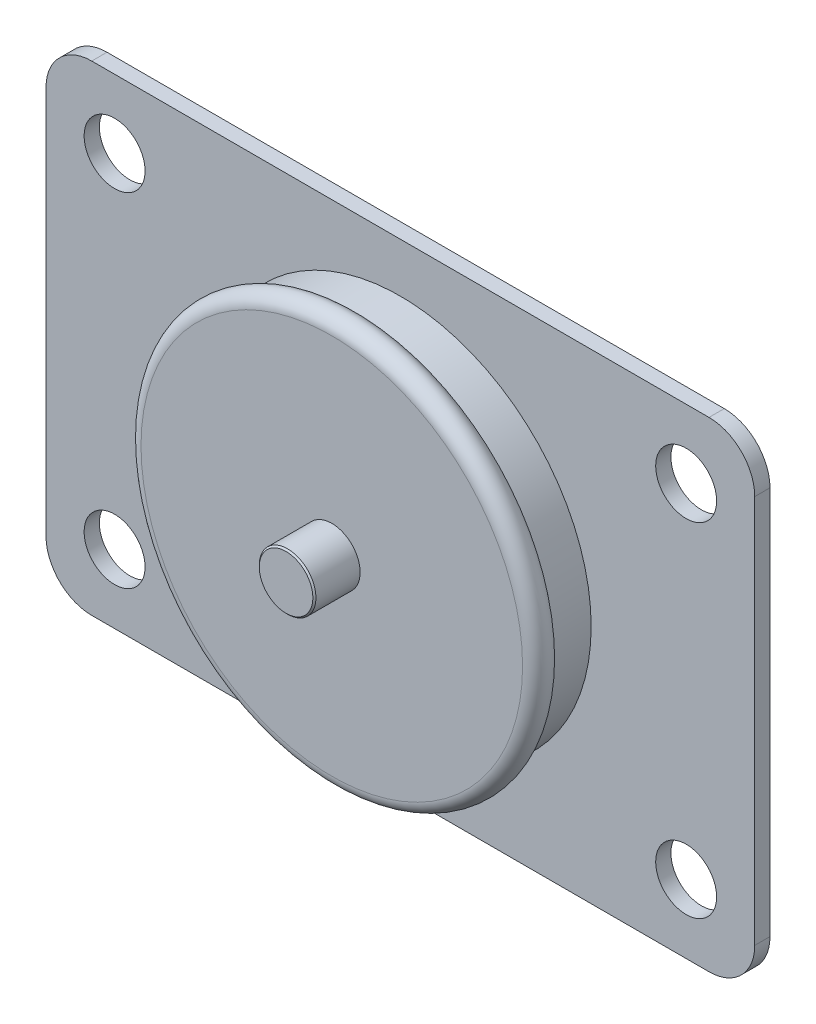
from build123d import *

# Parameters (mm, degrees)
EXTRUDE_1_DEPTH     = 2
SKETCH_4_R          = 25.034791669
EXTRUDE_2_DEPTH     = 9
SKETCH_5_R          = 1.739871364
SKETCH_7_R          = 3.716982855
EXTRUDE_3_DEPTH     = 6
CHAMFER_1_SIZE      = 0.2
SKETCH_9_R          = 25
CUT_EXTRUDE_2_DEPTH = 0.36
EXTRUDE_4_DEPTH     = 2
SKETCH_13_R         = 4
CUT_EXTRUDE_3_DEPTH = 35


with BuildPart() as part:
    # 草图1 → 凸台-拉伸1 (new body)
    with BuildSketch(Plane.XY):
        with BuildLine():
            Line((40.5, -31.5), (-40.5, -31.5))
            ThreePointArc((-40.5, -31.5), (-44.742640687, -29.742640687), (-46.5, -25.5))
            Line((-46.5, -25.5), (-46.5, 25.5))
            ThreePointArc((-46.5, 25.5), (-44.742640687, 29.742640687), (-40.5, 31.5))
            Line((-40.5, 31.5), (40.5, 31.5))
            ThreePointArc((40.5, 31.5), (44.742640687, 29.742640687), (46.5, 25.5))
            Line((46.5, 25.5), (46.5, -25.5))
            ThreePointArc((46.5, -25.5), (44.742640687, -29.742640687), (40.5, -31.5))
        make_face()
        with BuildLine():
            Line((-43.156854249, 22.5), (-37.5, 28.156854249))
            ThreePointArc((-37.5, 28.156854249), (-31.843145751, 28.156854249), (-31.843145751, 22.5))
            Line((-31.843145751, 22.5), (-37.5, 16.843145751))
            ThreePointArc((-37.5, 16.843145751), (-43.156854249, 16.843145751), (-43.156854249, 22.5))
        make_face(mode=Mode.SUBTRACT)
        with BuildLine():
            Line((37.5, 28.156854249), (43.156854249, 22.5))
            ThreePointArc((43.156854249, 22.5), (43.156854249, 16.843145751), (37.5, 16.843145751))
            Line((37.5, 16.843145751), (31.843145751, 22.5))
            ThreePointArc((31.843145751, 22.5), (31.843145751, 28.156854249), (37.5, 28.156854249))
        make_face(mode=Mode.SUBTRACT)
        with BuildLine():
            Line((31.843145751, -22.5), (37.5, -16.843145751))
            ThreePointArc((37.5, -16.843145751), (43.156854249, -16.843145751), (43.156854249, -22.5))
            Line((43.156854249, -22.5), (37.5, -28.156854249))
            ThreePointArc((37.5, -28.156854249), (31.843145751, -28.156854249), (31.843145751, -22.5))
        make_face(mode=Mode.SUBTRACT)
        with BuildLine():
            Line((-37.5, -28.156854249), (-43.156854249, -22.5))
            ThreePointArc((-43.156854249, -22.5), (-43.156854249, -16.843145751), (-37.5, -16.843145751))
            Line((-37.5, -16.843145751), (-31.843145751, -22.5))
            ThreePointArc((-31.843145751, -22.5), (-31.843145751, -28.156854249), (-37.5, -28.156854249))
        make_face(mode=Mode.SUBTRACT)
    extrude(amount=-EXTRUDE_1_DEPTH)

    # 草图4 → 凸台-拉伸2 (add)
    with BuildSketch(Plane.XY):
        Circle(SKETCH_4_R)
    extrude(amount=EXTRUDE_2_DEPTH)

    # 草图5 → 旋转2 (revolve)
    with BuildSketch(Plane(origin=(0, 0, 0), x_dir=(1, 0, 0), z_dir=(0, 1, 0))):
        with Locations((-25.034791669, -7.260128636)):
            Circle(SKETCH_5_R)
    revolve(axis=Axis((0, 0, 0), (0, 0, 1)))

    # 草图7 → 凸台-拉伸3 (add)
    with BuildSketch(Plane.XY.offset(9)):
        Circle(SKETCH_7_R)
    extrude(amount=EXTRUDE_3_DEPTH)

    # 倒角1
    chamfer_1_edges = [part.edges().sort_by_distance(p)[0] for p in [
        (-3.716982855, 0, 15),
    ]]
    chamfer(chamfer_1_edges, length=CHAMFER_1_SIZE)

    # 草图9 → 切除-拉伸2 (cut)
    with BuildSketch(Plane(origin=(0, 0, -2), x_dir=(-1, 0, 0), z_dir=(0, 0, -1))):
        Circle(SKETCH_9_R)
    extrude(amount=-CUT_EXTRUDE_2_DEPTH, mode=Mode.SUBTRACT)

    # 草图12 → 凸台-拉伸4 (add)
    with BuildSketch(Plane(origin=(0, 0, -2), x_dir=(-1, 0, 0), z_dir=(0, 0, -1))):
        with BuildLine():
            Line((37.5, 28.156854249), (43.156854249, 22.5))
            ThreePointArc((43.156854249, 22.5), (43.156854249, 16.843145751), (37.5, 16.843145751))
            Line((37.5, 16.843145751), (31.843145751, 22.5))
            ThreePointArc((31.843145751, 22.5), (31.843145751, 28.156854249), (37.5, 28.156854249))
        make_face()
        with BuildLine():
            Line((43.156854249, -22.5), (37.5, -28.156854249))
            ThreePointArc((37.5, -28.156854249), (31.843145751, -28.156854249), (31.843145751, -22.5))
            Line((31.843145751, -22.5), (37.5, -16.843145751))
            ThreePointArc((37.5, -16.843145751), (43.156854249, -16.843145751), (43.156854249, -22.5))
        make_face()
        with BuildLine():
            Line((-37.5, -28.156854249), (-43.156854249, -22.5))
            ThreePointArc((-43.156854249, -22.5), (-43.156854249, -16.843145751), (-37.5, -16.843145751))
            Line((-37.5, -16.843145751), (-31.843145751, -22.5))
            ThreePointArc((-31.843145751, -22.5), (-31.843145751, -28.156854249), (-37.5, -28.156854249))
        make_face()
        with BuildLine():
            Line((-43.156854249, 22.5), (-37.5, 28.156854249))
            ThreePointArc((-37.5, 28.156854249), (-31.843145751, 28.156854249), (-31.843145751, 22.5))
            Line((-31.843145751, 22.5), (-37.5, 16.843145751))
            ThreePointArc((-37.5, 16.843145751), (-43.156854249, 16.843145751), (-43.156854249, 22.5))
        make_face()
    extrude(amount=-EXTRUDE_4_DEPTH)

    # 草图13 → 切除-拉伸3 (cut)
    with BuildSketch(Plane(origin=(0, 0, -2), x_dir=(-1, 0, 0), z_dir=(0, 0, -1))):
        with Locations((-37.5, 22.5)):
            Circle(SKETCH_13_R)
        with Locations((-37.5, -22.5)):
            Circle(SKETCH_13_R)
        with Locations((37.5, -22.5)):
            Circle(SKETCH_13_R)
        with Locations((37.5, 22.5)):
            Circle(SKETCH_13_R)
    extrude(amount=-CUT_EXTRUDE_3_DEPTH, mode=Mode.SUBTRACT)


solid = part.part
